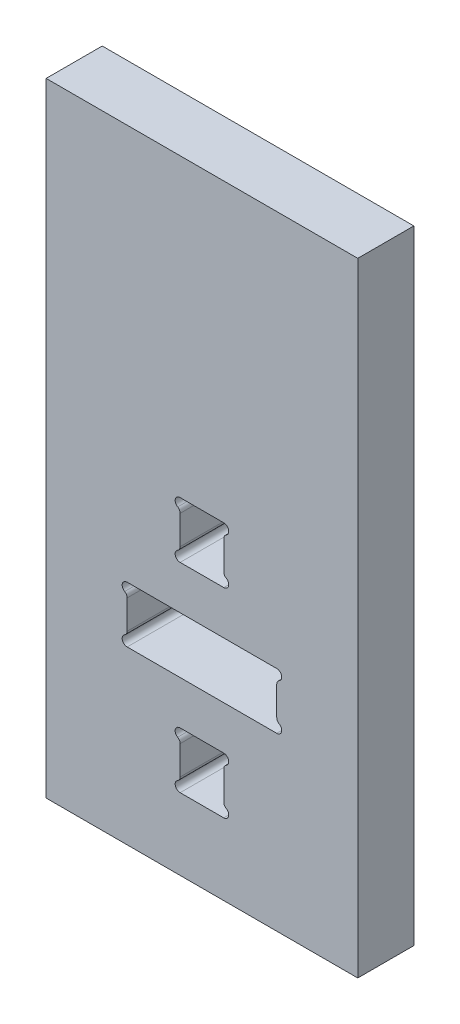
from build123d import *

# Parameters (mm, degrees)
SKETCH1_W           = 25
SKETCH1_H           = 50
BOSS_EXTRUDE1_DEPTH = 4.5
CUT_EXTRUDE1_DEPTH  = 4.5
LPATTERN1_COUNT     = 2
LPATTERN1_PITCH     = 16
CUT_EXTRUDE2_REACH  = 6.5


with BuildPart() as part:
    # Sketch1 → Boss-Extrude1 (new body)
    with BuildSketch(Plane.XY):
        with Locations((12.5, 25)):
            Rectangle(SKETCH1_W, SKETCH1_H)
    extrude(amount=BOSS_EXTRUDE1_DEPTH)

    # Sketch2 → Cut-Extrude1 (cut)
    with BuildSketch(Plane.XY.offset(4.5)):
        with BuildLine():
            Line((12.5, 10.25), (14.25, 10.25))
            ThreePointArc((14.25, 10.25), (14.636370331, 9.953527618), (14.45, 9.503589838))
            ThreePointArc((14.45, 9.503589838), (14.303589838, 9.357179677), (14.25, 9.157179677))
            Line((14.25, 9.157179677), (14.25, 8))
            Line((14.25, 8), (14.25, 6.842820323))
            ThreePointArc((14.25, 6.842820323), (14.303589838, 6.642820323), (14.45, 6.496410162))
            ThreePointArc((14.45, 6.496410162), (14.636370331, 6.046472382), (14.25, 5.75))
            Line((14.25, 5.75), (12.5, 5.75))
            Line((12.5, 5.75), (10.75, 5.75))
            ThreePointArc((10.75, 5.75), (10.363629669, 6.046472382), (10.55, 6.496410162))
            ThreePointArc((10.55, 6.496410162), (10.696410162, 6.642820323), (10.75, 6.842820323))
            Line((10.75, 6.842820323), (10.75, 8))
            Line((10.75, 8), (10.75, 9.157179677))
            ThreePointArc((10.75, 9.157179677), (10.696410162, 9.357179677), (10.55, 9.503589838))
            ThreePointArc((10.55, 9.503589838), (10.363629669, 9.953527618), (10.75, 10.25))
            Line((10.75, 10.25), (12.5, 10.25))
        make_face()
    cut_extrude1 = extrude(amount=-CUT_EXTRUDE1_DEPTH, mode=Mode.SUBTRACT)

    # LPattern1: Cut-Extrude1 ×2
    with Locations(*[(0, i * LPATTERN1_PITCH, 0) for i in range(1, LPATTERN1_COUNT)]):
        add(cut_extrude1, mode=Mode.SUBTRACT)

    # Sketch3 → Cut-Extrude2 (cut, up to next)
    with BuildSketch(Plane.XY.offset(4.5), mode=Mode.PRIVATE) as cut_extrude2_sk1:
        with BuildLine():
            Line((6.5, 18.25), (18.5, 18.25))
            ThreePointArc((18.5, 18.25), (18.886370331, 17.953527618), (18.7, 17.503589838))
            ThreePointArc((18.7, 17.503589838), (18.553589838, 17.357179677), (18.5, 17.157179677))
            Line((18.5, 17.157179677), (18.5, 14.842820323))
            ThreePointArc((18.5, 14.842820323), (18.553589838, 14.642820323), (18.7, 14.496410162))
            ThreePointArc((18.7, 14.496410162), (18.886370331, 14.046472382), (18.5, 13.75))
            Line((18.5, 13.75), (6.5, 13.75))
            ThreePointArc((6.5, 13.75), (6.113629669, 14.046472382), (6.3, 14.496410162))
            ThreePointArc((6.3, 14.496410162), (6.446410162, 14.642820323), (6.5, 14.842820323))
            Line((6.5, 14.842820323), (6.5, 17.157179677))
            ThreePointArc((6.5, 17.157179677), (6.446410162, 17.357179677), (6.3, 17.503589838))
            ThreePointArc((6.3, 17.503589838), (6.113629669, 17.953527618), (6.5, 18.25))
        make_face()
    cut_extrude2_tool1 = extrude(cut_extrude2_sk1.sketch, amount=-CUT_EXTRUDE2_REACH, mode=Mode.PRIVATE) & part.part
    add(cut_extrude2_tool1.solids().sort_by_distance((12.5, 16, 4.5))[0], mode=Mode.SUBTRACT)


solid = part.part
